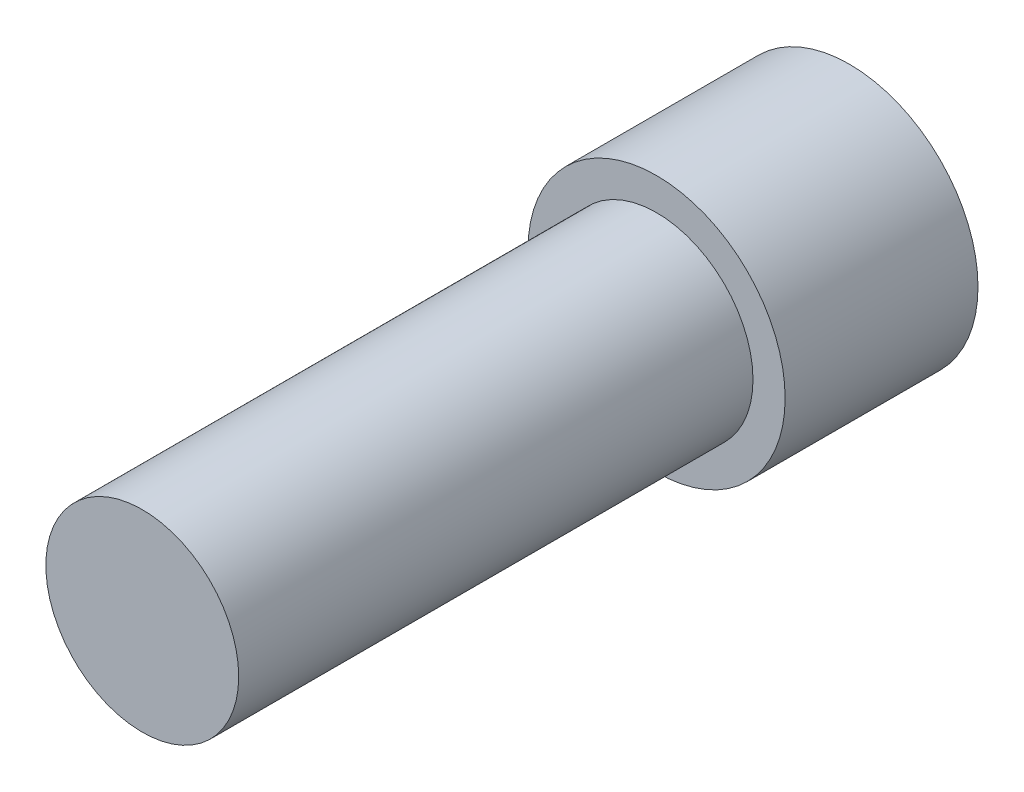
from build123d import *

# Parameters (mm, degrees)
SKETCH_1_R          = 2
EXTRUDE_1_DEPTH     = 3
SKETCH_2_R          = 1.5
EXTRUDE_2_DEPTH     = 8
CUT_EXTRUDE_1_DEPTH = 2


with BuildPart() as part:
    # 草图1 → 凸台-拉伸1 (new body)
    with BuildSketch(Plane.XY):
        Circle(SKETCH_1_R)
    extrude(amount=EXTRUDE_1_DEPTH)

    # 草图2 → 凸台-拉伸2 (add)
    with BuildSketch(Plane.XY.offset(3)):
        Circle(SKETCH_2_R)
    extrude(amount=EXTRUDE_2_DEPTH)

    # 草图3 → 切除-拉伸1 (cut)
    with BuildSketch(Plane(origin=(0, 0, 0), x_dir=(-1, 0, 0), z_dir=(0, 0, -1))):
        Polygon((1.513862997, -0.841557381), (1.485741569, 0.890265123), (-0.028121428, 1.731822504), (-1.513862997, 0.841557381), (-1.485741569, -0.890265123), (0.028121428, -1.731822504), align=None)
    extrude(amount=-CUT_EXTRUDE_1_DEPTH, mode=Mode.SUBTRACT)


solid = part.part
